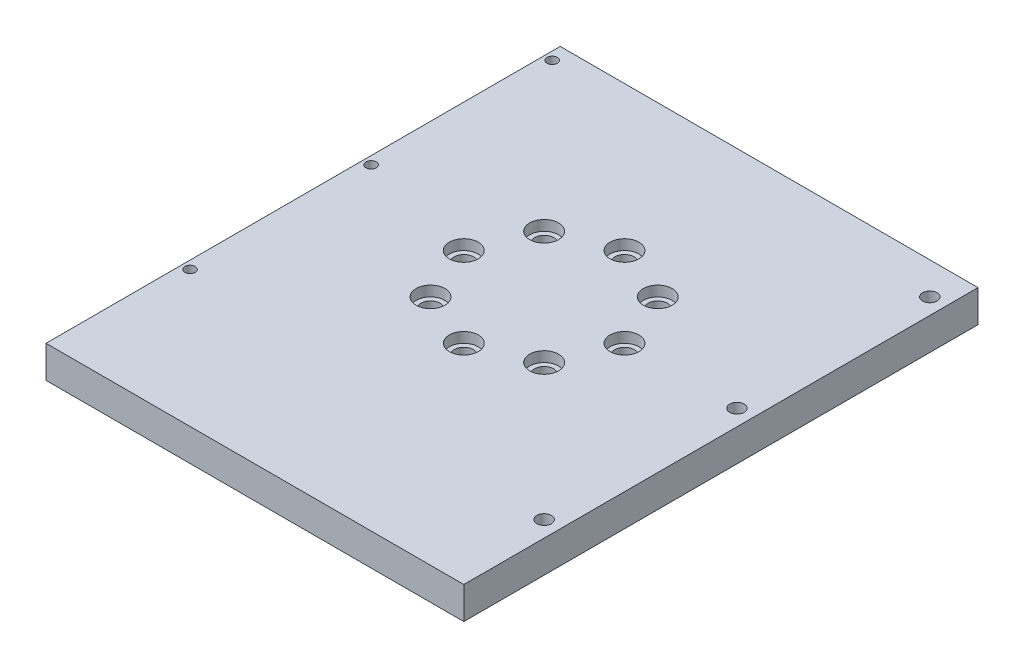
from build123d import *

# Parameters (mm, degrees)
SKETCH1_W           = 130
SKETCH1_H           = 160
SKETCH1_R           = 4.5
BOSS_EXTRUDE1_DEPTH = 10
SKETCH1_8_R         = 55
SKETCH1_8_R_2       = 45
BOSS_EXTRUDE2_DEPTH = 5
SKETCH1_9_R         = 4.5
SKETCH1_9_R_2       = 3
BOSS_EXTRUDE3_DEPTH = 6.8
SKETCH4_R           = 1.6
CUT_EXTRUDE1_DEPTH  = 10
SKETCH5_R           = 2.25
CUT_EXTRUDE2_DEPTH  = 10


with BuildPart() as part:
    # Sketch1 → Boss-Extrude1 (new body)
    with BuildSketch(Plane(origin=(0, 0, 0), x_dir=(1, 0, 0), z_dir=(0, 1, 0))):
        with Locations((0, -10)):
            Rectangle(SKETCH1_W, SKETCH1_H)
        with Locations((17.67766953, 17.67766953)):
            Circle(SKETCH1_R, mode=Mode.SUBTRACT)
        with Locations((25, 0)):
            Circle(SKETCH1_R, mode=Mode.SUBTRACT)
        with Locations((-17.67766953, -17.67766953)):
            Circle(SKETCH1_R, mode=Mode.SUBTRACT)
        with Locations((0, -25)):
            Circle(SKETCH1_R, mode=Mode.SUBTRACT)
        with Locations((17.67766953, -17.67766953)):
            Circle(SKETCH1_R, mode=Mode.SUBTRACT)
        with Locations((-25, 0)):
            Circle(SKETCH1_R, mode=Mode.SUBTRACT)
        with Locations((-17.67766953, 17.67766953)):
            Circle(SKETCH1_R, mode=Mode.SUBTRACT)
        with Locations((0, 25)):
            Circle(SKETCH1_R, mode=Mode.SUBTRACT)
    extrude(amount=BOSS_EXTRUDE1_DEPTH)

    # Sketch1_8 → Boss-Extrude2 (add)
    with BuildSketch(Plane(origin=(0, 0, 0), x_dir=(1, 0, 0), z_dir=(0, 1, 0))):
        Circle(SKETCH1_8_R)
        Circle(SKETCH1_8_R_2, mode=Mode.SUBTRACT)
    extrude(amount=-BOSS_EXTRUDE2_DEPTH)

    # Sketch1_9 → Boss-Extrude3 (add)
    with BuildSketch(Plane(origin=(0, 0, 0), x_dir=(1, 0, 0), z_dir=(0, 1, 0))):
        with Locations((17.67766953, -17.67766953)):
            Circle(SKETCH1_9_R)
        with Locations((17.67766953, -17.67766953)):
            Circle(SKETCH1_9_R_2, mode=Mode.SUBTRACT)
        with Locations((25, 0)):
            Circle(SKETCH1_9_R)
        with Locations((25, 0)):
            Circle(SKETCH1_9_R_2, mode=Mode.SUBTRACT)
        with Locations((17.67766953, 17.67766953)):
            Circle(SKETCH1_9_R)
        with Locations((17.67766953, 17.67766953)):
            Circle(SKETCH1_9_R_2, mode=Mode.SUBTRACT)
        with Locations((0, 25)):
            Circle(SKETCH1_9_R)
        with Locations((0, 25)):
            Circle(SKETCH1_9_R_2, mode=Mode.SUBTRACT)
        with Locations((-17.67766953, 17.67766953)):
            Circle(SKETCH1_9_R)
        with Locations((-17.67766953, 17.67766953)):
            Circle(SKETCH1_9_R_2, mode=Mode.SUBTRACT)
        with Locations((-25, 0)):
            Circle(SKETCH1_9_R)
        with Locations((-25, 0)):
            Circle(SKETCH1_9_R_2, mode=Mode.SUBTRACT)
        with Locations((-17.67766953, -17.67766953)):
            Circle(SKETCH1_9_R)
        with Locations((-17.67766953, -17.67766953)):
            Circle(SKETCH1_9_R_2, mode=Mode.SUBTRACT)
        with Locations((0, -25)):
            Circle(SKETCH1_9_R)
        with Locations((0, -25)):
            Circle(SKETCH1_9_R_2, mode=Mode.SUBTRACT)
    extrude(amount=BOSS_EXTRUDE3_DEPTH)

    # Sketch4 → Cut-Extrude1 (cut)
    with BuildSketch(Plane(origin=(0, 10, 0), x_dir=(1, 0, 0), z_dir=(0, 1, 0))):
        with Locations((-62.5, 65)):
            Circle(SKETCH4_R)
        with Locations((-62.5, 8.655)):
            Circle(SKETCH4_R)
        with Locations((-62.5, -47.69)):
            Circle(SKETCH4_R)
    extrude(amount=-CUT_EXTRUDE1_DEPTH, mode=Mode.SUBTRACT)

    # Sketch5 → Cut-Extrude2 (cut)
    with BuildSketch(Plane(origin=(0, 10, 0), x_dir=(1, 0, 0), z_dir=(0, 1, 0))):
        with Locations((60, 60)):
            Circle(SKETCH5_R)
        with Locations((60, 0)):
            Circle(SKETCH5_R)
        with Locations((60, -60)):
            Circle(SKETCH5_R)
    extrude(amount=-CUT_EXTRUDE2_DEPTH, mode=Mode.SUBTRACT)


solid = part.part
